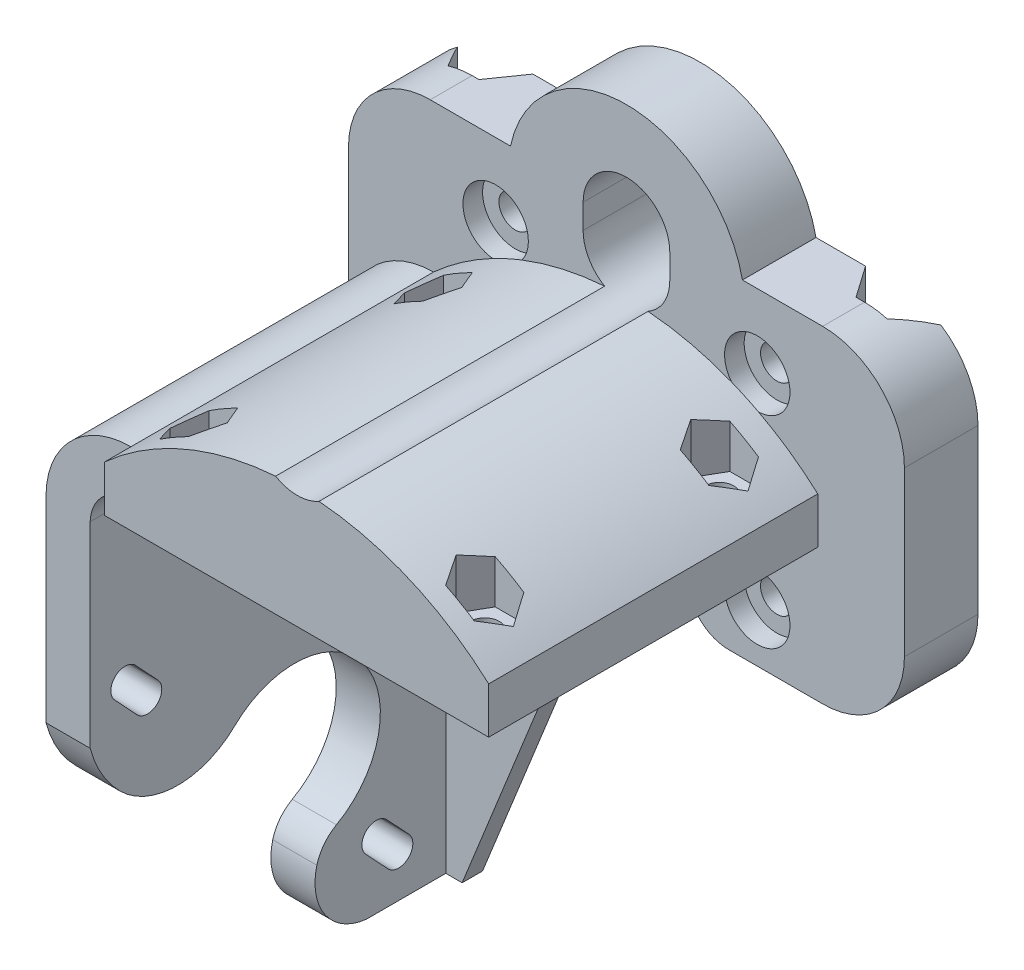
from build123d import *

# Parameters (mm, degrees)
SKETCH1_R                = 2
BOSS_EXTRUDE1_DEPTH      = 6.5
BOSS_EXTRUDE1_DEPTH_BACK = 2.5
BOSS_EXTRUDE3_DEPTH      = 2.5
FILLET2_R                = 10
SKETCH2_W                = 47
SKETCH2_H                = 5.65
BOSS_EXTRUDE4_DEPTH      = 40.25
SKETCH2_4_W              = 5.4
SKETCH2_4_H              = 11.5
BOSS_EXTRUDE5_DEPTH      = 37
SKETCH2_5_W              = 5.4
SKETCH2_5_H              = 47.5
BOSS_EXTRUDE6_DEPTH      = 37
BOSS_EXTRUDE6_DEPTH_BACK = 6.5
SKETCH4_R                = 4
CUT_EXTRUDE1_DEPTH       = 2.4
SKETCH5_R                = 1.75
CUT_EXTRUDE2_DEPTH       = 36.2
SKETCH5_4_R              = 1.75
CUT_EXTRUDE3_DEPTH       = 12
SKETCH5_5_R              = 1.75
BOSS_EXTRUDE7_DEPTH      = 5.65
LPATTERN2_COUNT          = 2
LPATTERN2_PITCH          = 28.7
MIRROR1_COPY_1_SKETCH_R  = 1.75
MIRROR1_COPY_1_DEPTH     = 36.2
MIRROR1_COPY_2_SKETCH_R  = 1.75
MIRROR1_COPY_2_DEPTH     = 12
MIRROR1_COPY_3_SKETCH_R  = 1.75
MIRROR1_COPY_3_DEPTH     = 5.65
MIRROR1_COPY_4_SKETCH_R  = 1.75
MIRROR1_COPY_4_DEPTH     = 36.2
SKETCH7_R                = 10.5
CUT_EXTRUDE4_DEPTH       = 5.65
FILLET3_R                = 10
FILLET5_R                = 5
FILLET6_R                = 5
FILLET12_R               = 5
CUT_EXTRUDE5_DEPTH       = 69
CUT_EXTRUDE7_DEPTH       = 40


with BuildPart() as part:
    # Sketch1 → Boss-Extrude1 (new body, two sides)
    with BuildSketch(Plane.XY) as boss_extrude1_sk:
        with BuildLine():
            ThreePointArc((7.5, -13.5), (0, -6), (-7.5, -13.5))
            Line((-7.5, -13.5), (-7.5, -20))
            Line((-7.5, -20), (-34, -20))
            Line((-34, -20), (-34, 20))
            Line((-34, 20), (-14.186260959, 20))
            ThreePointArc((-14.186260959, 20), (0, 31.5), (14.186260959, 20))
            Line((14.186260959, 20), (34, 20))
            Line((34, 20), (34, -20))
            Line((34, -20), (7.5, -20))
            Line((7.5, -20), (7.5, -13.5))
        make_face()
        with Locations((16, 11)):
            Circle(SKETCH1_R, mode=Mode.SUBTRACT)
        with Locations((-16, 11)):
            Circle(SKETCH1_R, mode=Mode.SUBTRACT)
        with Locations((16, -13.7)):
            Circle(SKETCH1_R, mode=Mode.SUBTRACT)
        with Locations((-16, -13.7)):
            Circle(SKETCH1_R, mode=Mode.SUBTRACT)
        with BuildLine():
            ThreePointArc((-5.3, 15.5), (0, 10.2), (5.3, 15.5))
            Line((5.3, 15.5), (5.3, 18.5))
            ThreePointArc((5.3, 18.5), (0, 23.8), (-5.3, 18.5))
            Line((-5.3, 18.5), (-5.3, 15.5))
        make_face(mode=Mode.SUBTRACT)
    extrude(amount=BOSS_EXTRUDE1_DEPTH)
    extrude(boss_extrude1_sk.sketch, amount=-BOSS_EXTRUDE1_DEPTH_BACK)

    # Sketch1_5 → Boss-Extrude3 (add)
    with BuildSketch(Plane.XY):
        Polygon((-34, -67.5), (-26.6, -67.5), (-7.5, -20), (-34, -20), align=None)
    extrude(amount=-BOSS_EXTRUDE3_DEPTH)

    # Fillet2
    fillet2_edges = [part.edges().sort_by_distance(p)[0] for p in [
        (-34, 20, 2),
        (34, 20, 2),
        (34, -20, 2),
    ]]
    fillet(fillet2_edges, radius=FILLET2_R)

    # Sketch2 → Boss-Extrude4 (add)
    with BuildSketch(Plane.XY.offset(6.5)):
        with Locations((-0.1, -0.875)):
            Rectangle(SKETCH2_W, SKETCH2_H)
        with BuildLine():
            Line((-23.6, 1.95), (23.4, 1.95))
            ThreePointArc((23.4, 1.95), (13.763613768, 8.149784472), (2.641305414, 10.905056506))
            ThreePointArc((2.641305414, 10.905056506), (-0.013421952, 10.200016995), (-2.664544331, 10.918493315))
            ThreePointArc((-2.664544331, 10.918493315), (-13.88218364, 8.184790241), (-23.6, 1.95))
        make_face()
    extrude(amount=BOSS_EXTRUDE4_DEPTH)

    # Sketch2_4 → Boss-Extrude5 (add)
    with BuildSketch(Plane.XY.offset(6.5)):
        with BuildLine():
            ThreePointArc((-23.6, -3.7), (-27.066660678, -5.093061794), (-28.6, -8.5))
            Line((-28.6, -8.5), (-34, -8.5))
            ThreePointArc((-34, -8.5), (-30.956929628, -1.12839061), (-23.6, 1.95))
            Line((-23.6, 1.95), (-23.6, -3.7))
        make_face()
        with Locations((-31.3, -14.25)):
            Rectangle(SKETCH2_4_W, SKETCH2_4_H)
    extrude(amount=BOSS_EXTRUDE5_DEPTH)

    # Sketch2_5 → Boss-Extrude6 (add, two sides)
    with BuildSketch(Plane.XY.offset(6.5)) as boss_extrude6_sk:
        with Locations((-31.3, -43.75)):
            Rectangle(SKETCH2_5_W, SKETCH2_5_H)
    extrude(amount=BOSS_EXTRUDE6_DEPTH)
    extrude(boss_extrude6_sk.sketch, amount=-BOSS_EXTRUDE6_DEPTH_BACK)

    # Sketch4 → Cut-Extrude1 (cut)
    with BuildSketch(Plane.XY.offset(6.5)):
        with Locations((-16, 11)):
            Circle(SKETCH4_R)
        with Locations((16, 11)):
            Circle(SKETCH4_R)
        with Locations((16, -13.7)):
            Circle(SKETCH4_R)
        with Locations((-16, -13.7)):
            Circle(SKETCH4_R)
    extrude(amount=-CUT_EXTRUDE1_DEPTH, mode=Mode.SUBTRACT)

    # Sketch5 → Cut-Extrude2 (cut, through all)
    with BuildSketch(Plane(origin=(0, -3.7, 0), x_dir=(-1, 0, 0), z_dir=(0, -1, 0))):
        with Locations((17.6, -12.531088913)):
            Circle(SKETCH5_R)
    cut_extrude2 = extrude(amount=-CUT_EXTRUDE2_DEPTH, mode=Mode.SUBTRACT)

    # Sketch5_4 → Cut-Extrude3 (cut)
    with BuildSketch(Plane(origin=(0, -3.7, 0), x_dir=(-1, 0, 0), z_dir=(0, -1, 0))):
        Polygon((15.85, -15.562177826), (19.35, -15.562177826), (21.1, -12.531088913), (19.35, -9.5), (15.85, -9.5), (14.1, -12.531088913), align=None)
        with Locations((17.6, -12.531088913)):
            Circle(SKETCH5_4_R, mode=Mode.SUBTRACT)
    cut_extrude3 = extrude(amount=-CUT_EXTRUDE3_DEPTH, mode=Mode.SUBTRACT)

    # Sketch5_5 → Boss-Extrude7 (add)
    with BuildSketch(Plane(origin=(0, -3.7, 0), x_dir=(-1, 0, 0), z_dir=(0, -1, 0))):
        Polygon((15.85, -15.562177826), (19.35, -15.562177826), (21.1, -12.531088913), (19.35, -9.5), (15.85, -9.5), (14.1, -12.531088913), align=None)
        with Locations((17.6, -12.531088913)):
            Circle(SKETCH5_5_R, mode=Mode.SUBTRACT)
    boss_extrude7 = extrude(amount=-BOSS_EXTRUDE7_DEPTH)

    # LPattern2: Cut-Extrude2, Cut-Extrude3, Boss-Extrude7 ×2
    with Locations(*[(0, 0, i * LPATTERN2_PITCH) for i in range(1, LPATTERN2_COUNT)]):
        add(cut_extrude2, mode=Mode.SUBTRACT)
        add(cut_extrude3, mode=Mode.SUBTRACT)
        add(boss_extrude7)

    # Mirror1: Cut-Extrude3, Boss-Extrude7 across plane
    add(cut_extrude3.mirror(Plane.ZY.offset(0.1)), mode=Mode.SUBTRACT)
    add(boss_extrude7.mirror(Plane.ZY.offset(0.1)))

    # Mirror1 copy 1 sketch → Mirror1 copy 1 (cut, through all)
    with BuildSketch(Plane(origin=(-0.2, -3.7, 28.7), x_dir=(1, 0, 0), z_dir=(0, -1, 0))):
        with Locations((17.6, 12.531088913)):
            Circle(MIRROR1_COPY_1_SKETCH_R)
    extrude(amount=-MIRROR1_COPY_1_DEPTH, mode=Mode.SUBTRACT)

    # Mirror1 copy 2 sketch → Mirror1 copy 2 (cut)
    with BuildSketch(Plane(origin=(-0.2, -3.7, 28.7), x_dir=(1, 0, 0), z_dir=(0, -1, 0))):
        Polygon((15.85, 15.562177826), (19.35, 15.562177826), (21.1, 12.531088913), (19.35, 9.5), (15.85, 9.5), (14.1, 12.531088913), align=None)
        with Locations((17.6, 12.531088913)):
            Circle(MIRROR1_COPY_2_SKETCH_R, mode=Mode.SUBTRACT)
    extrude(amount=-MIRROR1_COPY_2_DEPTH, mode=Mode.SUBTRACT)

    # Mirror1 copy 3 sketch → Mirror1 copy 3 (add)
    with BuildSketch(Plane(origin=(-0.2, -3.7, 28.7), x_dir=(1, 0, 0), z_dir=(0, -1, 0))):
        Polygon((15.85, 15.562177826), (19.35, 15.562177826), (21.1, 12.531088913), (19.35, 9.5), (15.85, 9.5), (14.1, 12.531088913), align=None)
        with Locations((17.6, 12.531088913)):
            Circle(MIRROR1_COPY_3_SKETCH_R, mode=Mode.SUBTRACT)
    extrude(amount=-MIRROR1_COPY_3_DEPTH)

    # Mirror1 copy 4 sketch → Mirror1 copy 4 (cut, through all)
    with BuildSketch(Plane(origin=(-0.2, -3.7, 0), x_dir=(1, 0, 0), z_dir=(0, -1, 0))):
        with Locations((17.6, 12.531088913)):
            Circle(MIRROR1_COPY_4_SKETCH_R)
    extrude(amount=-MIRROR1_COPY_4_DEPTH, mode=Mode.SUBTRACT)

    # Sketch7 → Cut-Extrude4 (cut)
    with BuildSketch(Plane.ZY.offset(34)):
        with BuildLine():
            ThreePointArc((28.34667488, -42.854044185), (28.835378228, -44.647985724), (29, -46.5))
            ThreePointArc((29, -46.5), (24.341660723, -55.224964183), (14.5, -56.208243919))
            ThreePointArc((14.5, -56.208243919), (15.43971668, -63.273798399), (9.7, -67.5))
            Line((9.7, -67.5), (43.5, -67.5))
            Line((43.5, -67.5), (43.5, -32.5))
            ThreePointArc((43.5, -32.5), (37.856610976, -40.506401793), (28.34667488, -42.854044185))
        make_face()
        with Locations((18.5, -46.5)):
            Circle(SKETCH7_R)
    extrude(amount=-CUT_EXTRUDE4_DEPTH, mode=Mode.SUBTRACT)

    # Fillet3
    fillet3_edges = [part.edges().sort_by_distance(p)[0] for p in [
        (-31.3, -42.854044185, 28.34667488),
    ]]
    fillet(fillet3_edges, radius=FILLET3_R)

    # Fillet5
    fillet5_edges = [part.edges().sort_by_distance(p)[0] for p in [
        (-31.3, -56.208243919, 14.5),
    ]]
    fillet(fillet5_edges, radius=FILLET5_R)

    # Fillet6
    fillet6_edges = [part.edges().sort_by_distance(p)[0] for p in [
        (7.5, -20, 2),
    ]]
    fillet(fillet6_edges, radius=FILLET6_R)

    # Fillet12
    fillet12_edges = [part.edges().sort_by_distance(p)[0] for p in [
        (-7.5, -20, 3.25),
    ]]
    fillet(fillet12_edges, radius=FILLET12_R)

    # Sketch10 → Cut-Extrude5 (cut, through all)
    with BuildSketch(Plane.ZY.offset(34)):
        with BuildLine():
            Line((6.88909431, -26.942221984), (9.812269185, -29.672615481))
            ThreePointArc((9.812269185, -29.672615481), (9.896611038, -32.146051644), (7.423174875, -32.230393497))
            Line((7.423174875, -32.230393497), (4.5, -29.5))
            ThreePointArc((4.5, -29.5), (4.415658147, -27.026563837), (6.88909431, -26.942221984))
        make_face()
        with BuildLine():
            Line((35.211828487, -29.423174875), (37.942221984, -26.5))
            ThreePointArc((37.942221984, -26.5), (40.415658147, -26.415658147), (40.5, -28.88909431))
            Line((40.5, -28.88909431), (37.769606503, -31.812269185))
            ThreePointArc((37.769606503, -31.812269185), (35.29617034, -31.896611038), (35.211828487, -29.423174875))
        make_face()
        with BuildLine():
            Line((9.788171513, -60.576825125), (7.057778016, -63.5))
            ThreePointArc((7.057778016, -63.5), (4.584341853, -63.584341853), (4.5, -61.11090569))
            Line((4.5, -61.11090569), (7.230393497, -58.187730815))
            ThreePointArc((7.230393497, -58.187730815), (9.70382966, -58.103388962), (9.788171513, -60.576825125))
        make_face()
    extrude(amount=-CUT_EXTRUDE5_DEPTH, mode=Mode.SUBTRACT)

    # Sketch11 → Cut-Extrude7 (cut)
    with BuildSketch(Plane(origin=(0, 20, 0), x_dir=(1, 0, 0), z_dir=(0, 1, 0))):
        Polygon((29.466805248, 2.5), (26.75, -1.38), (22.96, -1.38), (20.243194752, 2.5), align=None)
        Polygon((-20.443194752, 2.5), (-29.666805248, 2.5), (-26.95, -1.38), (-23.16, -1.38), align=None)
    extrude(amount=-CUT_EXTRUDE7_DEPTH, mode=Mode.SUBTRACT)


solid = part.part
